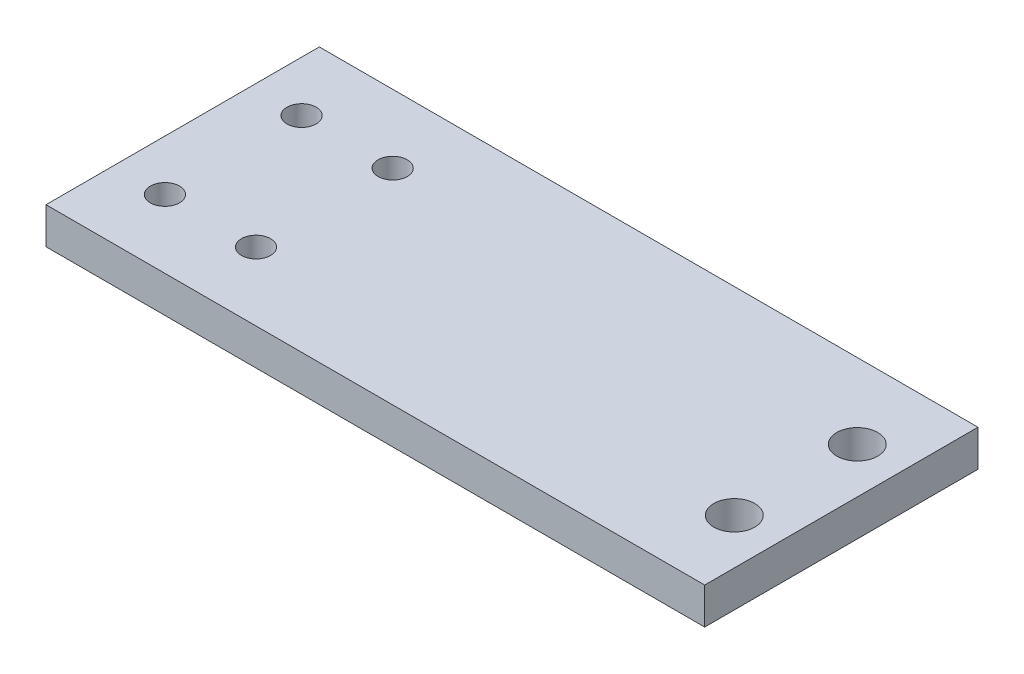
from build123d import *

# Parameters (mm, degrees)
SKETCH_1_W      = 72.302708202
SKETCH_1_H      = 30
SKETCH_1_R      = 1.6
SKETCH_1_R_2    = 2.25
EXTRUDE_1_DEPTH = 4


with BuildPart() as part:
    # 草图1 → 凸台-拉伸1 (new body)
    with BuildSketch(Plane(origin=(0, 0, 0), x_dir=(1, 0, 0), z_dir=(0, 1, 0))):
        with Locations((12.403157177, 7.998017492)):
            Rectangle(SKETCH_1_W, SKETCH_1_H)
        with Locations((-18.195488722, 15.498017492)):
            Circle(SKETCH_1_R, mode=Mode.SUBTRACT)
        with Locations((-18.195488722, 0.498017492)):
            Circle(SKETCH_1_R, mode=Mode.SUBTRACT)
        with Locations((-8.195488722, 15.498017492)):
            Circle(SKETCH_1_R, mode=Mode.SUBTRACT)
        with Locations((-8.195488722, 0.498017492)):
            Circle(SKETCH_1_R, mode=Mode.SUBTRACT)
        with Locations((43.554511278, 14.748017492)):
            Circle(SKETCH_1_R_2, mode=Mode.SUBTRACT)
        with Locations((43.554511278, 1.248017492)):
            Circle(SKETCH_1_R_2, mode=Mode.SUBTRACT)
    extrude(amount=EXTRUDE_1_DEPTH)


solid = part.part
